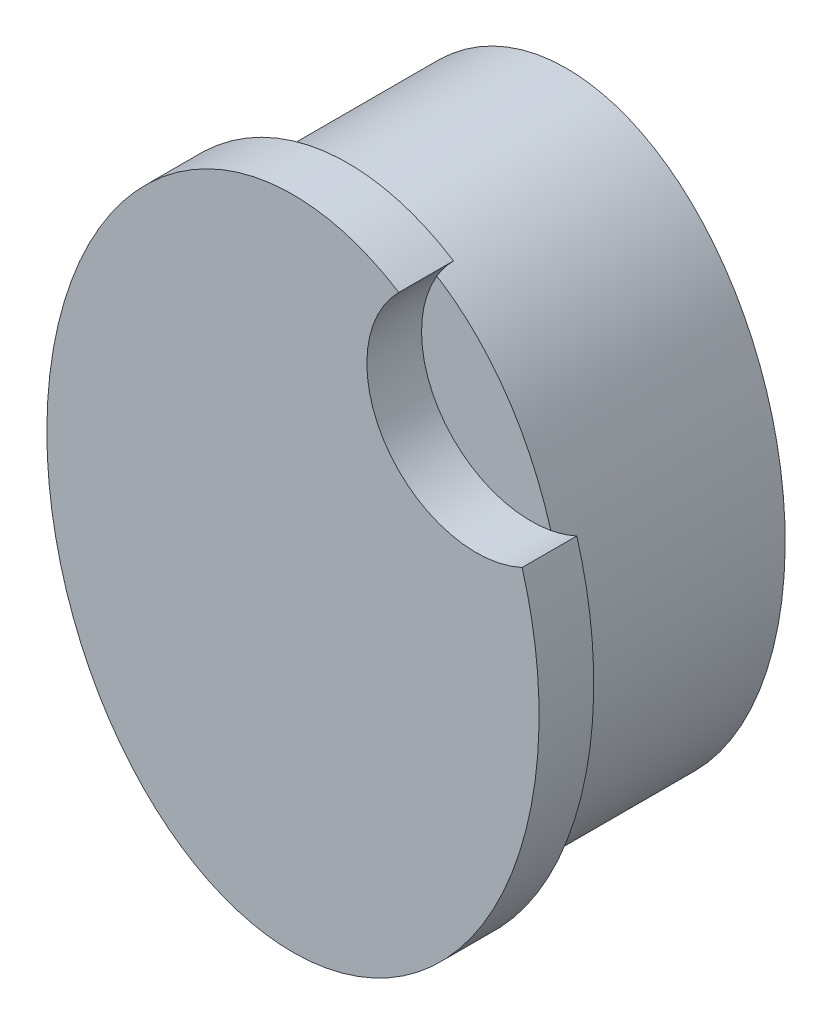
from build123d import *

# Parameters (mm, degrees)
CROQUIS1_RX             = 11
CROQUIS1_RY             = 8
SALIENTE_EXTRUIR1_DEPTH = 8
CROQUIS2_RX             = 12
CROQUIS2_RY             = 9
SALIENTE_EXTRUIR2_DEPTH = 2
CROQUIS3_R              = 4
CORTAR_EXTRUIR1_DEPTH   = 2


with BuildPart() as part:
    # Croquis1 → Saliente-Extruir1 (new body)
    with BuildSketch(Plane.XY):
        with Locations(Location((0, 0), (0, 0, 90))):
            Ellipse(CROQUIS1_RX, CROQUIS1_RY)
    extrude(amount=SALIENTE_EXTRUIR1_DEPTH)

    # Croquis2 → Saliente-Extruir2 (add)
    with BuildSketch(Plane.XY.offset(8)):
        with Locations(Location((0, 0), (0, 0, 90))):
            Ellipse(CROQUIS2_RX, CROQUIS2_RY)
    extrude(amount=SALIENTE_EXTRUIR2_DEPTH)

    # Croquis3 → Cortar-Extruir1 (cut)
    with BuildSketch(Plane.XY.offset(10)):
        with Locations((6.702388813, 8.008660223)):
            Circle(CROQUIS3_R)
    extrude(amount=-CORTAR_EXTRUIR1_DEPTH, mode=Mode.SUBTRACT)


solid = part.part
